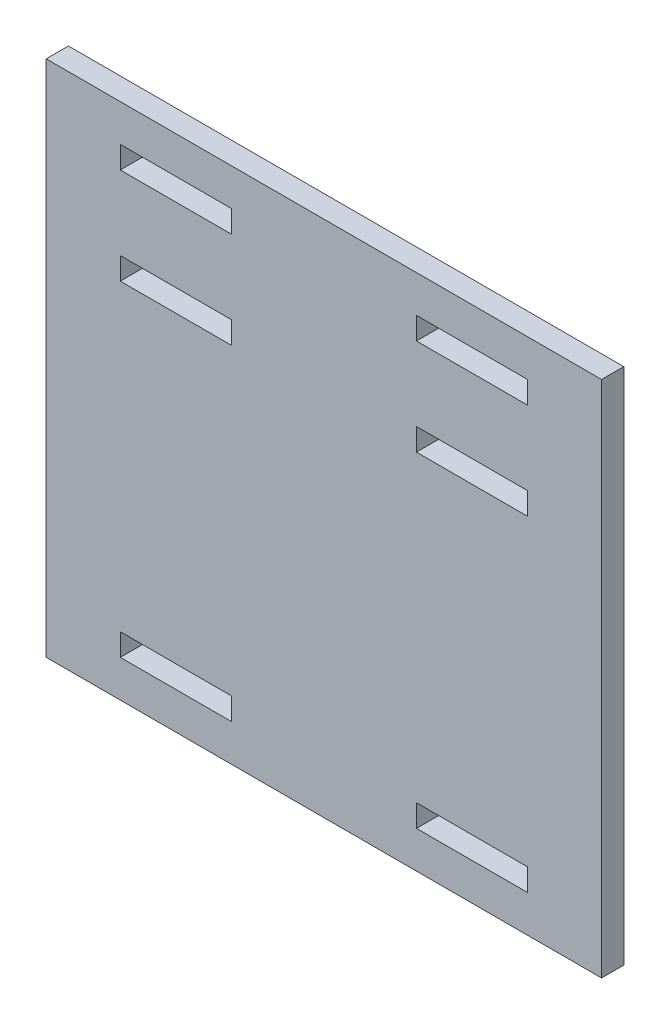
from build123d import *

# Parameters (mm, degrees)
ESQUISSE1_W        = 75
ESQUISSE1_H        = 70
ESQUISSE1_W_2      = 15
ESQUISSE1_H_2      = 3
BOSS_EXTRU_1_DEPTH = 3


with BuildPart() as part:
    # Esquisse1 → Boss.-Extru.1 (new body)
    with BuildSketch(Plane.XY):
        with Locations((-12.683673469, -2.836734694)):
            Rectangle(ESQUISSE1_W, ESQUISSE1_H)
        with Locations((-32.683673469, 25.663265306)):
            Rectangle(ESQUISSE1_W_2, ESQUISSE1_H_2, mode=Mode.SUBTRACT)
        with Locations((7.316326531, 25.663265306)):
            Rectangle(ESQUISSE1_W_2, ESQUISSE1_H_2, mode=Mode.SUBTRACT)
        with Locations((7.316326531, -31.336734694)):
            Rectangle(ESQUISSE1_W_2, ESQUISSE1_H_2, mode=Mode.SUBTRACT)
        with Locations((-32.683673469, -31.336734694)):
            Rectangle(ESQUISSE1_W_2, ESQUISSE1_H_2, mode=Mode.SUBTRACT)
        with Locations((-32.683673469, 12.663265306)):
            Rectangle(ESQUISSE1_W_2, ESQUISSE1_H_2, mode=Mode.SUBTRACT)
        with Locations((7.316326531, 12.663265306)):
            Rectangle(ESQUISSE1_W_2, ESQUISSE1_H_2, mode=Mode.SUBTRACT)
    extrude(amount=BOSS_EXTRU_1_DEPTH)


solid = part.part
